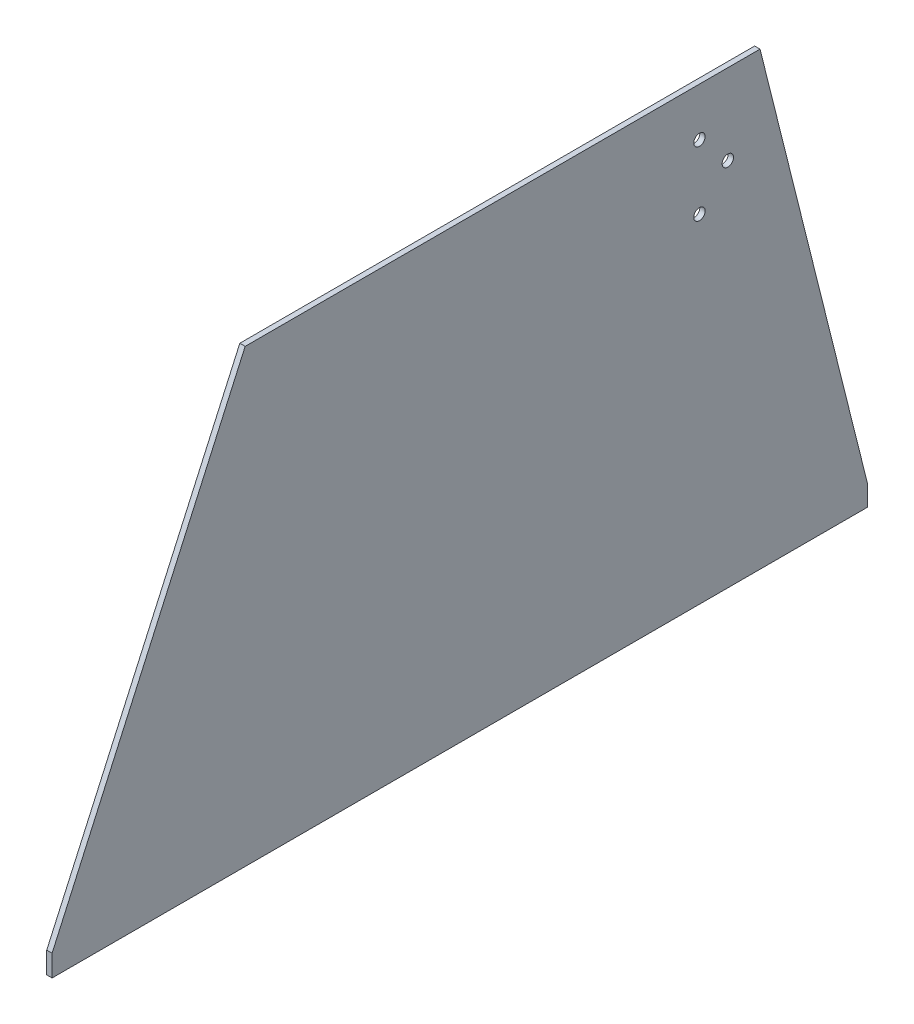
from build123d import *

# Parameters (mm, degrees)
BOSS_EXTRUDE1_DEPTH = 3.175
SKETCH3_R           = 3.3782
CUT_EXTRUDE2_DEPTH  = 4.175


with BuildPart() as part:
    # Sketch1 → Boss-Extrude1 (new body)
    with BuildSketch(Plane(origin=(0, 0, 0), x_dir=(0, 0, -1), z_dir=(1, 0, 0))):
        Polygon((114.3, 266.7), (419.1, 266.7), (482.6, 12.7), (482.6, 0), (0, 0), (0, 12.7), align=None)
    extrude(amount=BOSS_EXTRUDE1_DEPTH)

    # Sketch3 → Cut-Extrude2 (cut, through all)
    with BuildSketch(Plane(origin=(3.175, 0, 0), x_dir=(0, 0, -1), z_dir=(1, 0, 0))):
        with Locations((400.05, 219.075)):
            Circle(SKETCH3_R)
        with Locations((383.249479175, 200.025)):
            Circle(SKETCH3_R)
        with Locations((383.249479175, 238.125)):
            Circle(SKETCH3_R)
    extrude(amount=-CUT_EXTRUDE2_DEPTH, mode=Mode.SUBTRACT)


solid = part.part
